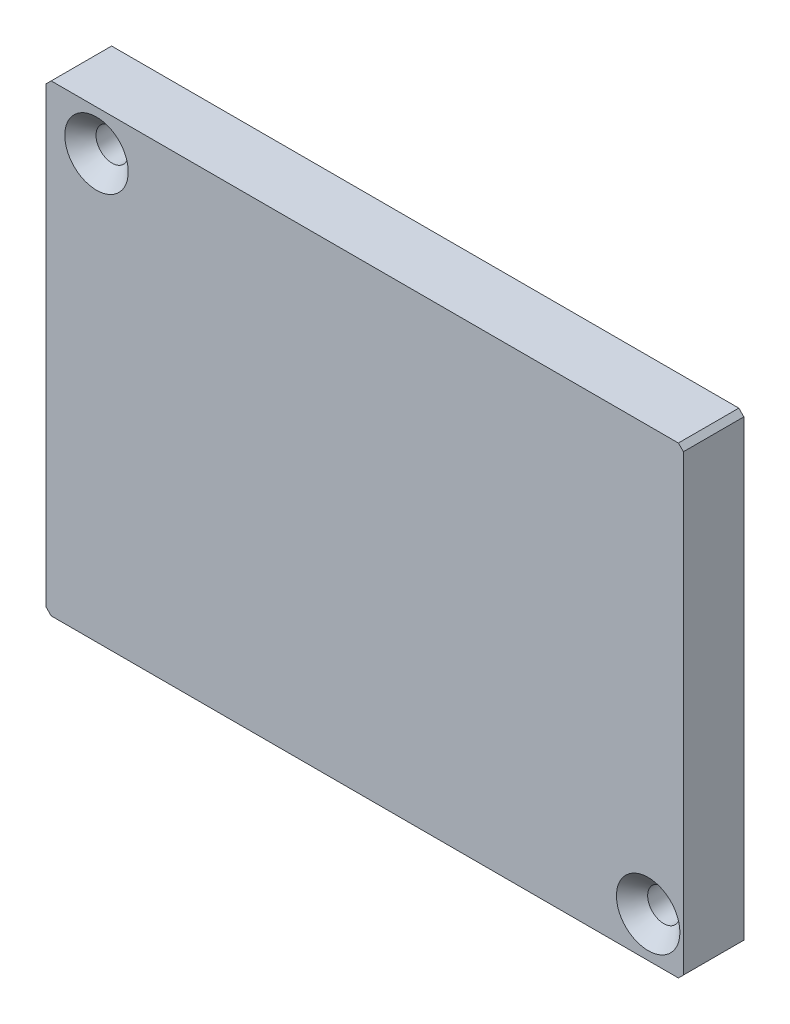
from build123d import *

# Parameters (mm, degrees)
P_IDAT_VYSUNUT_M2_DEPTH                           = 6
F_6_3_6_3_PR_M_R_D_RY1_D                          = 6.3
F_6_3_6_3_PR_M_R_D_RY1_DEPTH                      = 2
F_6_3_6_3_PR_M_R_D_RY1_CSINK_D                    = 6.4
F_6_3_6_3_PR_M_R_D_RY1_CSINK_ANGLE                = 90
F_6_3_6_3_PR_M_R_D_RY1_TIP                        = 1.89271095
KU_ELOV_ZAHLOUBEN_PRO_M3_ROUBU_SE_Z_P_D           = 3.2
KU_ELOV_ZAHLOUBEN_PRO_M3_ROUBU_SE_Z_P_DEPTH       = 6
KU_ELOV_ZAHLOUBEN_PRO_M3_ROUBU_SE_Z_P_CSINK_D     = 6.3
KU_ELOV_ZAHLOUBEN_PRO_M3_ROUBU_SE_Z_P_CSINK_ANGLE = 90


with BuildPart() as part:
    # Skica1 → Přidat vysunutím2 (new body)
    with BuildSketch(Plane.XY):
        Polygon((-326.879657855, 22.5), (-326.879657855, -22.5), (-326.379657855, -23), (-264.109857855, -23), (-263.609857855, -22.5), (-263.609857855, 22.5), (-264.109857855, 23), (-326.379657855, 23), align=None)
    extrude(amount=P_IDAT_VYSUNUT_M2_DEPTH)

    # Ø6.3 (6.3) průměr díry1
    with Locations(Plane(origin=(-321.879657855, -19, 0), x_dir=(-1, 0, 0), z_dir=(0, 0, -1))):
        with Locations((0, 0), (-54.7698, 38), (-45.2698, 27.8875), (-23.2698, 5.8875)):
            CounterSinkHole(F_6_3_6_3_PR_M_R_D_RY1_D / 2, F_6_3_6_3_PR_M_R_D_RY1_CSINK_D / 2, depth=F_6_3_6_3_PR_M_R_D_RY1_DEPTH, counter_sink_angle=F_6_3_6_3_PR_M_R_D_RY1_CSINK_ANGLE)
            with Locations((0, 0, -(F_6_3_6_3_PR_M_R_D_RY1_DEPTH + F_6_3_6_3_PR_M_R_D_RY1_TIP / 2))):  # 118° drill point
                Cone(0, F_6_3_6_3_PR_M_R_D_RY1_D / 2, F_6_3_6_3_PR_M_R_D_RY1_TIP, mode=Mode.SUBTRACT)

    # Kuželové zahloubení pro M3 šroubu se zápustnou hlavou plochou1
    with Locations(Plane(origin=(-321.879657855, 19, 6), x_dir=(1, 0, 0), z_dir=(0, 0, 1))):
        with Locations((0, 0), (54.7698, -38)):
            CounterSinkHole(KU_ELOV_ZAHLOUBEN_PRO_M3_ROUBU_SE_Z_P_D / 2, KU_ELOV_ZAHLOUBEN_PRO_M3_ROUBU_SE_Z_P_CSINK_D / 2, depth=KU_ELOV_ZAHLOUBEN_PRO_M3_ROUBU_SE_Z_P_DEPTH, counter_sink_angle=KU_ELOV_ZAHLOUBEN_PRO_M3_ROUBU_SE_Z_P_CSINK_ANGLE)


solid = part.part
